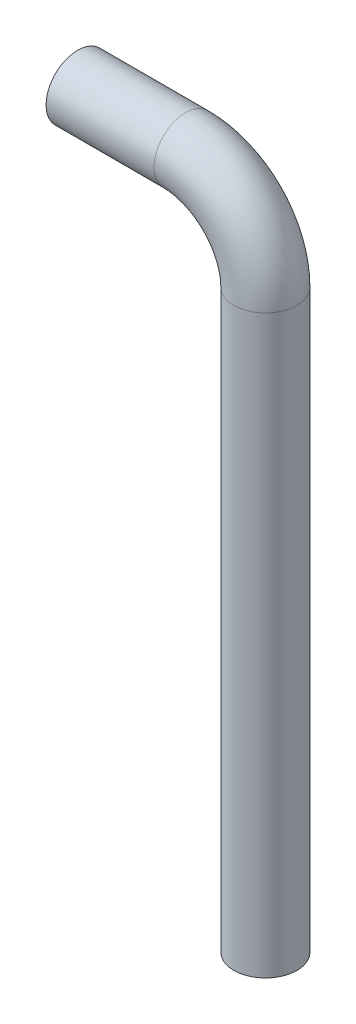
from build123d import *

# Parameters (mm, degrees)
SKETCH5_R           = 22.225
SKETCH5_R_2         = 19.05
SKETCH6_R           = 22.225
SKETCH6_R_2         = 19.05
BOSS_EXTRUDE1_DEPTH = 76.2
SKETCH7_R           = 22.225
SKETCH7_R_2         = 19.05
BOSS_EXTRUDE2_DEPTH = 406.4


with BuildPart() as part:
    # Sweep1: sweep along a path in Sketch4
    with BuildLine(Plane.XY) as sweep1_path:
        ThreePointArc((56.324038217, 0), (39.827109367, 39.827109367), (0, 56.324038217))
    # Sketch5 → Sweep1 (sweep)
    with BuildSketch(Plane(origin=(0, 0, 0), x_dir=(1, 0, 0), z_dir=(0, 1, 0))):
        with Locations((56.324038217, 0)):
            Circle(SKETCH5_R)
        with Locations((56.324038217, 0)):
            Circle(SKETCH5_R_2, mode=Mode.SUBTRACT)
    sweep(path=sweep1_path.line)

    # Sketch6 → Boss-Extrude1 (add)
    with BuildSketch(Plane.ZY):
        with Locations((0, 56.324038217)):
            Circle(SKETCH6_R)
        with Locations((0, 56.324038217)):
            Circle(SKETCH6_R_2, mode=Mode.SUBTRACT)
    extrude(amount=BOSS_EXTRUDE1_DEPTH)

    # Sketch7 → Boss-Extrude2 (add)
    with BuildSketch(Plane.XZ):
        with Locations((56.324038217, 0)):
            Circle(SKETCH7_R)
        with Locations((56.324038217, 0)):
            Circle(SKETCH7_R_2, mode=Mode.SUBTRACT)
    extrude(amount=BOSS_EXTRUDE2_DEPTH)


solid = part.part
